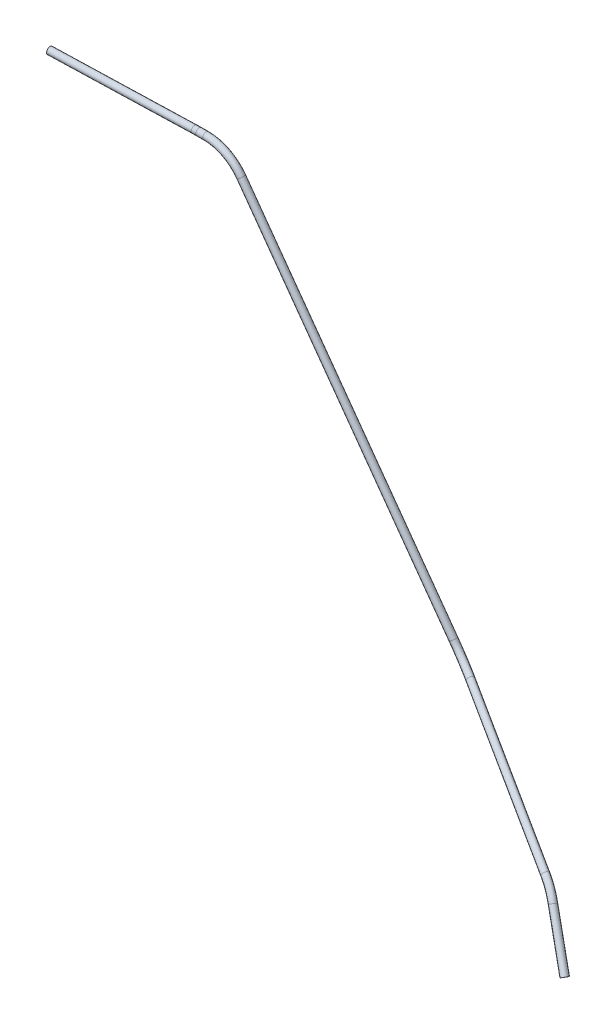
from build123d import *

# Parameters (mm, degrees)
SZKIC1_R   = 3.25
SZKIC1_R_2 = 1.75


with BuildPart() as part:
    # Wyciągnięcie po ścieżce4: sweep along a curve in space
    with BuildLine() as wyci_gni_cie_po_cie_ce4_path:
        Line((101.002175739, -599.755205595, 230.41246958), (74.850696308, -559.116516703, 215.546064653))
        ThreePointArc((59.504530347, -546.867351488, 207.340867047), (68.089990081, -551.58603587, 211.835850617), (74.850696308, -559.116516703, 215.546064653))
        Line((-88.374063747, -496.723607563, 131.310132464), (59.504530347, -546.867351488, 207.340867047))
        ThreePointArc((-111.816027792, -478.149064418, 124.40695353), (-101.261916385, -489.591337463, 126.022515141), (-88.374063747, -496.723607563, 131.310132464))
        Line((-307.527245601, -187.948009553, 132.258208808), (-111.816027792, -478.149064418, 124.40695353))
        ThreePointArc((-307.527245601, -187.948009553, 132.258208808), (-321.911039025, -174.996735159, 132.608599545), (-340.694228743, -170.314051144, 132.735287394))
        Line((-340.694228743, -170.314051144, 132.735287394), (-347.455121341, -170.314051144, 132.735287394))
        ThreePointArc((-347.455121341, -170.314051144, 132.735287394), (-349.69039399, -170.279594721, 132.787436726), (-351.918680923, -170.176333137, 132.943721743))
        Line((-351.918680923, -170.176333137, 132.943721743), (-478.784997122, -162.32310334, 144.829479287))
    # Szkic1 → Wyciągnięcie po ścieżce4 (sweep)
    with BuildSketch(Plane(origin=(101.002175739, -599.755205595, 230.41246958), x_dir=(0.8533828719682364, 0.5104047203493964, -0.10594666241226798), z_dir=(-0.5172264929682565, 0.8037559247680768, -0.29402919646180037))):
        Circle(SZKIC1_R)
        Circle(SZKIC1_R_2, mode=Mode.SUBTRACT)
    sweep(path=wyci_gni_cie_po_cie_ce4_path.line)


solid = part.part
